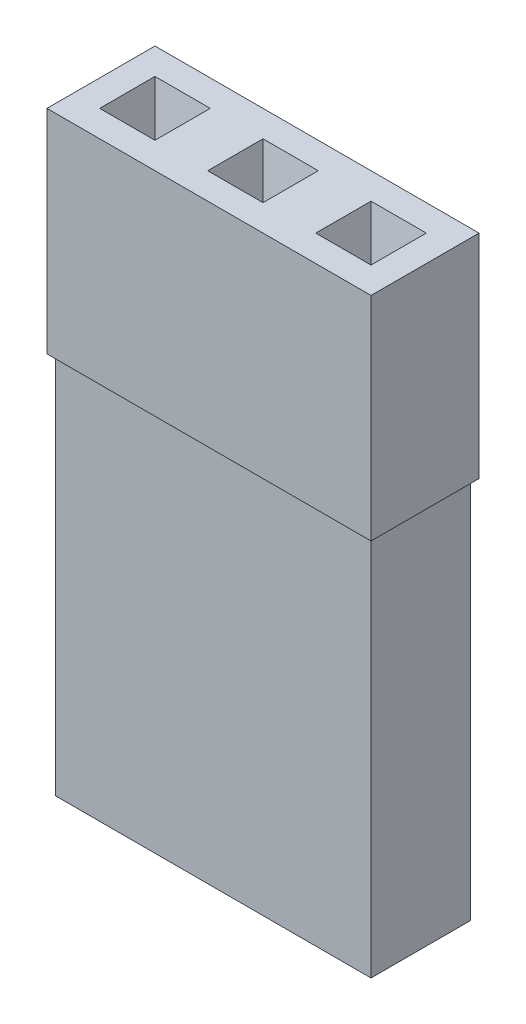
from build123d import *

# Parameters (mm, degrees)
SKIZZE1_W                       = 7.62
SKIZZE1_H                       = 2.54
SKIZZE1_W_2                     = 0.7
SKIZZE1_H_2                     = 0.7
AUFSATZ_LINEAR_AUSTRAGEN1_DEPTH = 14
SKIZZE3_OUTSIDE_W               = 12.848
SKIZZE3_OUTSIDE_H               = 7.768
SKIZZE3_OUTSIDE_W_2             = 7.42
SKIZZE3_OUTSIDE_H_2             = 2.34
SCHNITT_LINEAR_AUSTRAGEN1_DEPTH = 9
FASE1_SIZE                      = 0.3
FASE1_SIZE2                     = 1.701384546
FASE1_PART_2_SIZE               = 0.3
FASE1_PART_2_SIZE2              = 1.701384546


with BuildPart() as part:
    # Skizze1 → Aufsatz-Linear austragen1 (new body)
    with BuildSketch(Plane(origin=(0, 0, 0), x_dir=(1, 0, 0), z_dir=(0, 1, 0))):
        Rectangle(SKIZZE1_W, SKIZZE1_H)
        with Locations((-2.54, 0)):
            Rectangle(SKIZZE1_W_2, SKIZZE1_H_2, mode=Mode.SUBTRACT)
        Rectangle(SKIZZE1_W_2, SKIZZE1_H_2, mode=Mode.SUBTRACT)
        with Locations((2.54, 0)):
            Rectangle(SKIZZE1_W_2, SKIZZE1_H_2, mode=Mode.SUBTRACT)
    extrude(amount=AUFSATZ_LINEAR_AUSTRAGEN1_DEPTH)

    # Skizze3 outside → Schnitt-Linear austragen1 (cut)
    with BuildSketch(Plane.XZ):
        Rectangle(SKIZZE3_OUTSIDE_W, SKIZZE3_OUTSIDE_H)
        Rectangle(SKIZZE3_OUTSIDE_W_2, SKIZZE3_OUTSIDE_H_2, mode=Mode.SUBTRACT)
    extrude(amount=-SCHNITT_LINEAR_AUSTRAGEN1_DEPTH, mode=Mode.SUBTRACT)

    # Fase1
    fase1_edges = [part.edges().sort_by_distance(p)[0] for p in [
        (-2.89, 0, 0),
        (-2.54, 0, 0.35),
        (-2.19, 0, 0),
        (-2.54, 0, -0.35),
        (-0.35, 0, 0),
        (0, 0, 0.35),
        (0.35, 0, 0),
        (0, 0, -0.35),
        (2.19, 0, 0),
        (2.54, 0, 0.35),
        (2.89, 0, 0),
        (2.54, 0, -0.35),
    ]]
    fase1_side = [part.faces().sort_by_distance(p)[0] for p in [
        (0, 0, -1.092197686),
    ]]
    chamfer(fase1_edges, length=FASE1_SIZE, length2=FASE1_SIZE2, reference=fase1_side[0])

    # Fase1 part 2
    fase1_part_2_edges = [part.edges().sort_by_distance(p)[0] for p in [
        (-2.89, 14, 0),
        (-2.54, 14, 0.35),
        (-2.19, 14, 0),
        (-2.54, 14, -0.35),
        (-0.35, 14, 0),
        (0, 14, 0.35),
        (0.35, 14, 0),
        (0, 14, -0.35),
        (2.19, 14, 0),
        (2.54, 14, 0.35),
        (2.89, 14, 0),
        (2.54, 14, -0.35),
    ]]
    fase1_part_2_side = [part.faces().sort_by_distance(p)[0] for p in [
        (0, 14, 1.189678147),
    ]]
    chamfer(fase1_part_2_edges, length=FASE1_PART_2_SIZE, length2=FASE1_PART_2_SIZE2, reference=fase1_part_2_side[0])


solid = part.part
